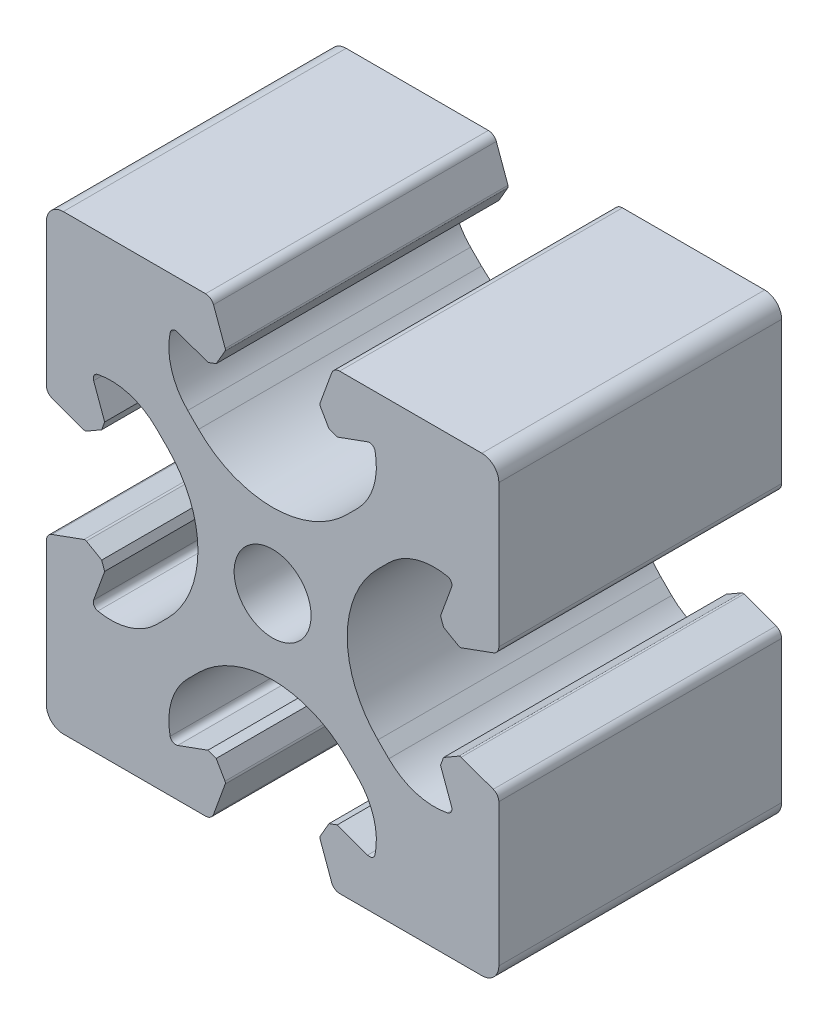
from build123d import *

# Parameters (mm, degrees)
SK_MAIN_EXTRUSION_R  = 3.4
MAIN_EXTRUSION_DEPTH = 25


with BuildPart() as part:
    # Sk Main Extrusion → Main Extrusion (new body)
    with BuildSketch(Plane.XY):
        with BuildLine():
            Line((4.190076845, -16.671180212), (5.222054351, -19.506515107))
            ThreePointArc((5.222054351, -19.506515107), (5.496641489, -19.864364033), (5.926823816, -20))
            Line((5.926823816, -20), (18.5, -20))
            ThreePointArc((18.5, -20), (19.560660172, -19.560660172), (20, -18.5))
            Line((20, -18.5), (20, -5.926823816))
            ThreePointArc((20, -5.926823816), (19.864364033, -5.496641489), (19.506515107, -5.222054351))
            Line((19.506515107, -5.222054351), (16.671180212, -4.190076845))
            ThreePointArc((16.671180212, -4.190076845), (16.563886241, -4.175951325), (16.460675177, -4.208493649))
            Line((16.460675177, -4.208493649), (15.111296024, -4.987558066))
            Line((15.111296024, -4.987558066), (14.845251581, -5.718509166))
            Line((14.845251581, -5.718509166), (15.81984631, -8.396186179))
            ThreePointArc((15.81984631, -8.396186179), (15.786489799, -8.811074612), (15.450654467, -9.056960151))
            ThreePointArc((15.450654467, -9.056960151), (12.665882372, -8.933433013), (10.272684887, -7.504160339))
            Line((10.272684887, -7.504160339), (9.309262274, -6.540737726))
            ThreePointArc((9.309262274, -6.540737726), (6.6, 0), (9.309262274, 6.540737726))
            Line((9.309262274, 6.540737726), (10.272684887, 7.504160339))
            ThreePointArc((10.272684887, 7.504160339), (12.665882372, 8.933433013), (15.450654467, 9.056960151))
            ThreePointArc((15.450654467, 9.056960151), (15.786489799, 8.811074612), (15.81984631, 8.396186179))
            Line((15.81984631, 8.396186179), (14.845251581, 5.718509166))
            Line((14.845251581, 5.718509166), (15.111296024, 4.987558066))
            Line((15.111296024, 4.987558066), (16.460675176, 4.208493649))
            ThreePointArc((16.460675176, 4.208493649), (16.563886241, 4.175951325), (16.671180212, 4.190076845))
            Line((16.671180212, 4.190076845), (19.506515107, 5.222054351))
            ThreePointArc((19.506515107, 5.222054351), (19.864364033, 5.496641489), (20, 5.926823816))
            Line((20, 5.926823816), (20, 18.5))
            ThreePointArc((20, 18.5), (19.560660172, 19.560660172), (18.5, 20))
            Line((18.5, 20), (5.926823816, 20))
            ThreePointArc((5.926823816, 20), (5.496641489, 19.864364033), (5.222054351, 19.506515107))
            Line((5.222054351, 19.506515107), (4.190076845, 16.671180212))
            ThreePointArc((4.190076845, 16.671180212), (4.175951325, 16.563886241), (4.208493649, 16.460675176))
            Line((4.208493649, 16.460675176), (4.987558066, 15.111296024))
            Line((4.987558066, 15.111296024), (5.718509166, 14.845251581))
            Line((5.718509166, 14.845251581), (8.396186179, 15.81984631))
            ThreePointArc((8.396186179, 15.81984631), (8.811074612, 15.786489799), (9.056960151, 15.450654467))
            ThreePointArc((9.056960151, 15.450654467), (8.933433013, 12.665882372), (7.504160339, 10.272684887))
            Line((7.504160339, 10.272684887), (6.540737726, 9.309262274))
            ThreePointArc((6.540737726, 9.309262274), (0, 6.6), (-6.540737726, 9.309262274))
            Line((-6.540737726, 9.309262274), (-7.504160339, 10.272684887))
            ThreePointArc((-7.504160339, 10.272684887), (-8.933433013, 12.665882372), (-9.056960151, 15.450654467))
            ThreePointArc((-9.056960151, 15.450654467), (-8.811074612, 15.786489799), (-8.396186179, 15.81984631))
            Line((-8.396186179, 15.81984631), (-5.718509166, 14.845251581))
            Line((-5.718509166, 14.845251581), (-4.987558066, 15.111296024))
            Line((-4.987558066, 15.111296024), (-4.208493649, 16.460675177))
            ThreePointArc((-4.208493649, 16.460675177), (-4.175951325, 16.563886241), (-4.190076845, 16.671180212))
            Line((-4.190076845, 16.671180212), (-5.222054351, 19.506515107))
            ThreePointArc((-5.222054351, 19.506515107), (-5.496641489, 19.864364033), (-5.926823816, 20))
            Line((-5.926823816, 20), (-18.5, 20))
            ThreePointArc((-18.5, 20), (-19.560660172, 19.560660172), (-20, 18.5))
            Line((-20, 18.5), (-20, 5.926823816))
            ThreePointArc((-20, 5.926823816), (-19.864364033, 5.496641489), (-19.506515107, 5.222054351))
            Line((-19.506515107, 5.222054351), (-16.671180212, 4.190076845))
            ThreePointArc((-16.671180212, 4.190076845), (-16.563886241, 4.175951325), (-16.460675177, 4.208493649))
            Line((-16.460675177, 4.208493649), (-15.111296024, 4.987558066))
            Line((-15.111296024, 4.987558066), (-14.845251581, 5.718509166))
            Line((-14.845251581, 5.718509166), (-15.81984631, 8.396186179))
            ThreePointArc((-15.81984631, 8.396186179), (-15.786489799, 8.811074612), (-15.450654467, 9.056960151))
            ThreePointArc((-15.450654467, 9.056960151), (-12.665882372, 8.933433013), (-10.272684887, 7.504160339))
            Line((-10.272684887, 7.504160339), (-9.309262274, 6.540737726))
            ThreePointArc((-9.309262274, 6.540737726), (-6.6, 0), (-9.309262274, -6.540737726))
            Line((-9.309262274, -6.540737726), (-10.272684887, -7.504160339))
            ThreePointArc((-10.272684887, -7.504160339), (-12.665882372, -8.933433013), (-15.450654467, -9.056960151))
            ThreePointArc((-15.450654467, -9.056960151), (-15.786489799, -8.811074612), (-15.81984631, -8.396186179))
            Line((-15.81984631, -8.396186179), (-14.845251581, -5.718509166))
            Line((-14.845251581, -5.718509166), (-15.111296024, -4.987558066))
            Line((-15.111296024, -4.987558066), (-16.460675177, -4.208493649))
            ThreePointArc((-16.460675177, -4.208493649), (-16.563886241, -4.175951325), (-16.671180212, -4.190076845))
            Line((-16.671180212, -4.190076845), (-19.506515107, -5.222054351))
            ThreePointArc((-19.506515107, -5.222054351), (-19.864364033, -5.496641489), (-20, -5.926823816))
            Line((-20, -5.926823816), (-20, -18.5))
            ThreePointArc((-20, -18.5), (-19.560660172, -19.560660172), (-18.5, -20))
            Line((-18.5, -20), (-5.926823816, -20))
            ThreePointArc((-5.926823816, -20), (-5.496641489, -19.864364033), (-5.222054351, -19.506515107))
            Line((-5.222054351, -19.506515107), (-4.190076845, -16.671180212))
            ThreePointArc((-4.190076845, -16.671180212), (-4.175951325, -16.563886241), (-4.208493649, -16.460675177))
            Line((-4.208493649, -16.460675177), (-4.987558066, -15.111296024))
            Line((-4.987558066, -15.111296024), (-5.718509166, -14.845251581))
            Line((-5.718509166, -14.845251581), (-8.396186179, -15.81984631))
            ThreePointArc((-8.396186179, -15.81984631), (-8.811074612, -15.786489799), (-9.056960151, -15.450654467))
            ThreePointArc((-9.056960151, -15.450654467), (-8.933433013, -12.665882372), (-7.504160339, -10.272684887))
            Line((-7.504160339, -10.272684887), (-6.540737726, -9.309262274))
            ThreePointArc((-6.540737726, -9.309262274), (0, -6.6), (6.540737726, -9.309262274))
            Line((6.540737726, -9.309262274), (7.504160339, -10.272684887))
            ThreePointArc((7.504160339, -10.272684887), (8.933433013, -12.665882372), (9.056960151, -15.450654467))
            ThreePointArc((9.056960151, -15.450654467), (8.811074612, -15.786489799), (8.396186179, -15.81984631))
            Line((8.396186179, -15.81984631), (5.718509166, -14.845251581))
            Line((5.718509166, -14.845251581), (4.987558066, -15.111296024))
            Line((4.987558066, -15.111296024), (4.208493649, -16.460675177))
            ThreePointArc((4.208493649, -16.460675177), (4.175951325, -16.563886241), (4.190076845, -16.671180212))
        make_face()
        Circle(SK_MAIN_EXTRUSION_R, mode=Mode.SUBTRACT)
    extrude(amount=-MAIN_EXTRUSION_DEPTH)


solid = part.part
